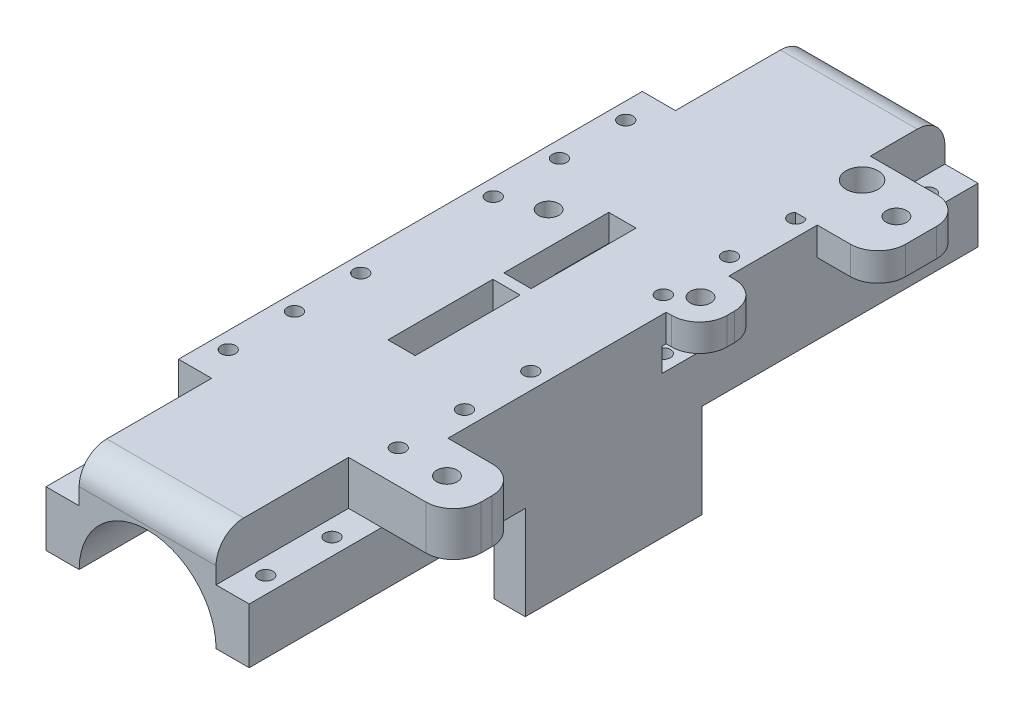
from build123d import *

# Parameters (mm, degrees)
BOSS_EXTRU_1_DEPTH      = 132
ESQUISSE3_W             = 4.94012132
ESQUISSE3_H             = 40
ENL_V_MAT_EXTRU_2_DEPTH = 9
ESQUISSE4_R             = 1.3
ENL_V_MAT_EXTRU_3_DEPTH = 18
ESQUISSE5_W             = 6
ESQUISSE5_H             = 24
ENL_V_MAT_EXTRU_4_DEPTH = 8
BOSS_EXTRU_2_REACH      = 38.8
ESQUISSE7_W             = 2
ESQUISSE7_H             = 18
ENL_V_MAT_EXTRU_5_DEPTH = 15
ENL_V_MAT_EXTRU_6_DEPTH = 15
ESQUISSE10_W            = 5.625
ESQUISSE10_H            = 32
BOSS_EXTRU_3_DEPTH      = 17
ESQUISSE12_W            = 12
ESQUISSE12_H            = 8
BOSS_EXTRU_4_DEPTH      = 13
ESQUISSE14_W            = 11.349962924
ESQUISSE14_H            = 7.588006138
BOSS_EXTRU_5_DEPTH      = 6
ESQUISSE16_W            = 13.258712606
ESQUISSE16_H            = 4.272246905
ENL_V_MAT_EXTRU_7_DEPTH = 11
ESQUISSE17_W            = 15.613345165
ESQUISSE17_H            = 5.100882875
BOSS_EXTRU_6_DEPTH      = 11
BOSS_EXTRU_6_DEPTH_BACK = 11
ESQUISSE11_R            = 1.85
ESQUISSE11_R_2          = 1.3
ESQUISSE11_R_3          = 2.916438904
ENL_V_MAT_EXTRU_8_DEPTH = 8
CONG_1_R                = 5
ESQUISSE18_W            = 9.677736186
ESQUISSE18_H            = 8.253244783
ENL_V_MAT_EXTRU_9_DEPTH = 10
CONG_2_R                = 5


with BuildPart() as part:
    # Esquisse1 → Boss.-Extru.1 (new body)
    with BuildSketch(Plane.XY):
        with BuildLine():
            Line((-12.4, 0), (-18.4, 0))
            Line((-18.4, 0), (-18.4, 18))
            Line((-18.4, 18), (18.4, 18))
            Line((18.4, 18), (18.4, 0))
            Line((18.4, 0), (12.4, 0))
            ThreePointArc((12.4, 0), (0, 12.4), (-12.4, 0))
        make_face()
    extrude(amount=BOSS_EXTRU_1_DEPTH)

    # Esquisse3 → Enlèv. mat.-Extru.2 (cut)
    with BuildSketch(Plane.XZ.offset(-18)):
        with Locations((0, 66)):
            Rectangle(ESQUISSE3_W, ESQUISSE3_H)
    extrude(amount=ENL_V_MAT_EXTRU_2_DEPTH, mode=Mode.SUBTRACT)

    # Esquisse4 → Enlèv. mat.-Extru.3 (cut)
    with BuildSketch(Plane(origin=(0, 18, 0), x_dir=(1, 0, 0), z_dir=(0, 1, 0))):
        with Locations((15.4, -6)):
            Circle(ESQUISSE4_R)
        with Locations((15.4, -18)):
            Circle(ESQUISSE4_R)
        with Locations((-15.4, -6)):
            Circle(ESQUISSE4_R)
        with Locations((-15.4, -18)):
            Circle(ESQUISSE4_R)
        with Locations((15.4, -30)):
            Circle(ESQUISSE4_R)
        with Locations((-15.4, -30)):
            Circle(ESQUISSE4_R)
        with Locations((15.4, -42)):
            Circle(ESQUISSE4_R)
        with Locations((-15.4, -42)):
            Circle(ESQUISSE4_R)
        with Locations((15.4, -54)):
            Circle(ESQUISSE4_R)
        with Locations((-15.4, -54)):
            Circle(ESQUISSE4_R)
        with Locations((-15.4, -126)):
            Circle(ESQUISSE4_R)
        with Locations((-15.4, -114)):
            Circle(ESQUISSE4_R)
        with Locations((-15.4, -102)):
            Circle(ESQUISSE4_R)
        with Locations((-15.4, -90)):
            Circle(ESQUISSE4_R)
        with Locations((-15.4, -78)):
            Circle(ESQUISSE4_R)
        with Locations((15.4, -78)):
            Circle(ESQUISSE4_R)
        with Locations((15.4, -90)):
            Circle(ESQUISSE4_R)
        with Locations((15.4, -102)):
            Circle(ESQUISSE4_R)
        with Locations((15.4, -114)):
            Circle(ESQUISSE4_R)
        with Locations((15.4, -126)):
            Circle(ESQUISSE4_R)
    extrude(amount=-ENL_V_MAT_EXTRU_3_DEPTH, mode=Mode.SUBTRACT)

    # Esquisse5 → Enlèv. mat.-Extru.4 (cut)
    with BuildSketch(Plane(origin=(0, 18, 0), x_dir=(1, 0, 0), z_dir=(0, 1, 0))):
        with Locations((15.4, -12)):
            Rectangle(ESQUISSE5_W, ESQUISSE5_H)
        with Locations((-15.4, -120)):
            Rectangle(ESQUISSE5_W, ESQUISSE5_H)
        with Locations((-15.4, -12)):
            Rectangle(ESQUISSE5_W, ESQUISSE5_H)
        with Locations((15.4, -120)):
            Rectangle(ESQUISSE5_W, ESQUISSE5_H)
    extrude(amount=-ENL_V_MAT_EXTRU_4_DEPTH, mode=Mode.SUBTRACT)

    # Esquisse7 → Boss.-Extru.2 (add, up to next)
    with BuildSketch(Plane.ZY.offset(18.4), mode=Mode.PRIVATE) as boss_extru_2_sk1:
        with Locations((66, 9)):
            Rectangle(ESQUISSE7_W, ESQUISSE7_H)
    boss_extru_2_tool1 = extrude(boss_extru_2_sk1.sketch, amount=-BOSS_EXTRU_2_REACH, mode=Mode.PRIVATE) - part.part
    add(boss_extru_2_tool1.solids().sort_by_distance((-18.4, 9, 66))[0])

    # Esquisse8 → Enlèv. mat.-Extru.5 (cut)
    with BuildSketch(Plane(origin=(0, 0, 65), x_dir=(-1, 0, 0), z_dir=(0, 0, -1))):
        with BuildLine():
            Line((12.775, 0), (-12.775, 0))
            ThreePointArc((-12.775, 0), (0, 12.775), (12.775, 0))
        make_face()
    extrude(amount=ENL_V_MAT_EXTRU_5_DEPTH, mode=Mode.SUBTRACT)

    # Esquisse9 → Enlèv. mat.-Extru.6 (cut)
    with BuildSketch(Plane.XY.offset(67)):
        with BuildLine():
            Line((12.775, 0), (-12.775, 0))
            ThreePointArc((-12.775, 0), (0, 12.775), (12.775, 0))
        make_face()
    extrude(amount=ENL_V_MAT_EXTRU_6_DEPTH, mode=Mode.SUBTRACT)

    # Esquisse10 → Boss.-Extru.3 (add)
    with BuildSketch(Plane.XZ):
        with Locations((15.5875, 66)):
            Rectangle(ESQUISSE10_W, ESQUISSE10_H)
        with Locations((-15.5875, 66)):
            Rectangle(ESQUISSE10_W, ESQUISSE10_H)
    extrude(amount=BOSS_EXTRU_3_DEPTH)

    # Esquisse12 → Boss.-Extru.4 (add)
    with BuildSketch(Plane(origin=(18.4, 0, 0), x_dir=(0, 0, -1), z_dir=(1, 0, 0))):
        with Locations((-102, 14)):
            Rectangle(ESQUISSE12_W, ESQUISSE12_H)
    extrude(amount=BOSS_EXTRU_4_DEPTH)

    # Esquisse14 → Boss.-Extru.5 (add)
    with BuildSketch(Plane(origin=(18.4, 0, 0), x_dir=(0, 0, -1), z_dir=(1, 0, 0))):
        with Locations((-50.7944077, 14.205996931)):
            Rectangle(ESQUISSE14_W, ESQUISSE14_H)
    extrude(amount=BOSS_EXTRU_5_DEPTH)

    # Esquisse16 → Enlèv. mat.-Extru.7 (cut)
    with BuildSketch(Plane(origin=(24.4, 0, 0), x_dir=(0, 0, -1), z_dir=(1, 0, 0))):
        with Locations((-50.566594151, 10.91391733)):
            Rectangle(ESQUISSE16_W, ESQUISSE16_H)
    extrude(amount=-ENL_V_MAT_EXTRU_7_DEPTH, mode=Mode.SUBTRACT)

    # Esquisse17 → Boss.-Extru.6 (add, two sides)
    with BuildSketch(Plane(origin=(18.4, 0, 0), x_dir=(0, 0, -1), z_dir=(1, 0, 0))) as boss_extru_6_sk:
        with Locations((-21.308135783, 15.449558563)):
            Rectangle(ESQUISSE17_W, ESQUISSE17_H)
    extrude(amount=BOSS_EXTRU_6_DEPTH)
    extrude(boss_extru_6_sk.sketch, amount=-BOSS_EXTRU_6_DEPTH_BACK)

    # Esquisse11 → Enlèv. mat.-Extru.8 (cut)
    with BuildSketch(Plane(origin=(0, 18, 0), x_dir=(1, 0, 0), z_dir=(0, 1, 0))):
        with Locations((24.22, -102)):
            Circle(ESQUISSE11_R)
        with Locations((19.13, -51)):
            Circle(ESQUISSE11_R)
        with Locations((24.22, -20.6)):
            Circle(ESQUISSE11_R)
        with Locations((-8.37, -51)):
            Circle(ESQUISSE11_R)
        with Locations((15.4, -6)):
            Circle(ESQUISSE11_R_2)
        with Locations((15.4, -18)):
            Circle(ESQUISSE11_R_3)
    extrude(amount=-ENL_V_MAT_EXTRU_8_DEPTH, mode=Mode.SUBTRACT)

    # Congé1
    cong_1_edges = [part.edges().sort_by_distance(p)[0] for p in [
        (29.4, 15.449558563, 13.5014632),
        (24.4, 15.525020391, 45.119426238),
        (24.4, 15.525020391, 56.469389162),
        (31.4, 14, 96),
        (31.4, 14, 108),
        (29.4, 15.449558563, 29.114808365),
    ]]
    fillet(cong_1_edges, radius=CONG_1_R)

    # Esquisse18 → Enlèv. mat.-Extru.9 (cut)
    with BuildSketch(Plane(origin=(-2.47006066, 0, 0), x_dir=(0, 0, -1), z_dir=(1, 0, 0))):
        with Locations((-50.900131157, 9.01339788)):
            Rectangle(ESQUISSE18_W, ESQUISSE18_H)
    extrude(amount=-ENL_V_MAT_EXTRU_9_DEPTH, mode=Mode.SUBTRACT)

    # Congé2
    cong_2_edges = [part.edges().sort_by_distance(p)[0] for p in [
        (0, 18, 0),
        (0, 18, 132),
    ]]
    fillet(cong_2_edges, radius=CONG_2_R)


solid = part.part
